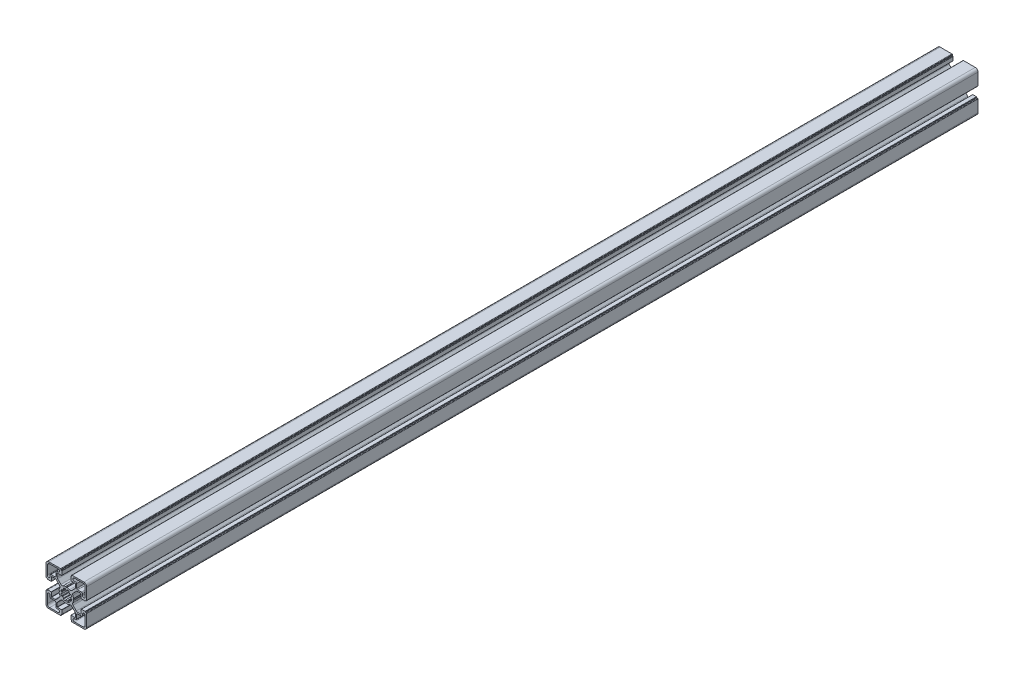
from build123d import *

# Parameters (mm, degrees)
BASE_EXTRUDE_DEPTH = 988


with BuildPart() as part:
    # Sketch1 → Base-Extrude (new body)
    with BuildSketch(Plane.XY):
        with BuildLine():
            Line((7.973976585, 0.792591518), (7.540060475, 0.046829556))
            ThreePointArc((7.540060475, 0.046829556), (7.534295984, 0.023675638), (7.531329941, 0))
            ThreePointArc((7.531329941, 0), (7.534295984, -0.023675638), (7.540060475, -0.046829556))
            Line((7.540060475, -0.046829556), (7.973976585, -0.792591518))
            ThreePointArc((7.973976585, -0.792591518), (7.996666421, -0.851255641), (8.000014047, -0.914065683))
            ThreePointArc((8.000014047, -0.914065683), (7.719730741, -2.298395946), (7.20036345, -3.611859543))
            ThreePointArc((7.20036345, -3.611859543), (7.018857217, -4.793954471), (7.563483933, -5.85869607))
            Line((7.563483933, -5.85869607), (11.129779889, -9.424988026))
            ThreePointArc((11.129779889, -9.424988026), (11.760624613, -9.84650461), (12.504756513, -9.99452154))
            Line((12.504756513, -9.99452154), (16.316902451, -9.99452154))
            ThreePointArc((16.316902451, -9.99452154), (16.458324055, -9.935942793), (16.516902802, -9.794521189))
            Line((16.516902802, -9.794521189), (16.516902802, -5.200014226))
            ThreePointArc((16.516902802, -5.200014226), (16.575481548, -5.058592621), (16.716903152, -5.000013875))
            Line((16.716903152, -5.000013875), (20.719599904, -5.000013875))
            ThreePointArc((20.719599904, -5.000013875), (20.931731427, -5.087881629), (21.01959918, -5.300013151))
            Line((21.01959918, -5.300013151), (21.01959918, -5.500004099))
            ThreePointArc((21.01959918, -5.500004099), (21.10746708, -5.712135974), (21.319598956, -5.800003874))
            Line((21.319598956, -5.800003874), (21.999979514, -5.800003874))
            ThreePointArc((21.999979514, -5.800003874), (22.35353264, -5.946450374), (22.49997914, -6.300003501))
            Line((22.49997914, -6.300003501), (22.49997914, -19.500016116))
            ThreePointArc((22.49997914, -19.500016116), (21.62130014, -21.621334875), (19.499981381, -22.500013875))
            Line((19.499981381, -22.500013875), (6.375709012, -22.500013875))
            ThreePointArc((6.375709012, -22.500013875), (6.022155886, -22.353567375), (5.875709386, -22.000014249))
            Line((5.875709386, -22.000014249), (5.875709386, -21.30001315))
            ThreePointArc((5.875709386, -21.30001315), (5.787841632, -21.087881628), (5.57571011, -21.000013874))
            Line((5.57571011, -21.000013874), (5.299998776, -21.000013874))
            ThreePointArc((5.299998776, -21.000013874), (5.087867607, -20.912146267), (5, -20.700015099))
            Line((5, -20.700015099), (5, -16.666812433))
            ThreePointArc((5, -16.666812433), (5.058578893, -16.525390475), (5.200000851, -16.466811582))
            Line((5.200000851, -16.466811582), (9.905385218, -16.466811582))
            ThreePointArc((9.905385218, -16.466811582), (10.046806822, -16.408232835), (10.105385569, -16.266811231))
            Line((10.105385569, -16.266811231), (10.105385569, -12.471582956))
            ThreePointArc((10.105385569, -12.471582956), (9.953144588, -11.706215861), (9.519598955, -11.057368968))
            Line((9.519598955, -11.057368968), (5.944897989, -7.482668002))
            ThreePointArc((5.944897989, -7.482668002), (4.854601835, -6.967833724), (3.666499237, -7.173289937))
            ThreePointArc((3.666499237, -7.173289937), (2.309136684, -7.713848333), (0.876396038, -8.000013875))
            ThreePointArc((0.876396038, -8.000013875), (0.81356491, -7.997088573), (0.754749577, -7.974793627))
            Line((0.754749577, -7.974793627), (0.11262846, -7.606936933))
            ThreePointArc((0.11262846, -7.606936933), (0.062963903, -7.559088739), (0, -7.530953975))
            ThreePointArc((0, -7.530953975), (-0.062963903, -7.559088739), (-0.11262846, -7.606936933))
            Line((-0.11262846, -7.606936933), (-0.754749577, -7.974793627))
            ThreePointArc((-0.754749577, -7.974793627), (-0.81356491, -7.997088573), (-0.876396038, -8.000013875))
            ThreePointArc((-0.876396038, -8.000013875), (-2.309136684, -7.713848333), (-3.666499237, -7.173289937))
            ThreePointArc((-3.666499237, -7.173289937), (-4.854601835, -6.967833724), (-5.944897989, -7.482668002))
            Line((-5.944897989, -7.482668002), (-9.519598955, -11.057368968))
            ThreePointArc((-9.519598955, -11.057368968), (-9.953144588, -11.706215861), (-10.105385569, -12.471582956))
            Line((-10.105385569, -12.471582956), (-10.105385569, -16.266811231))
            ThreePointArc((-10.105385569, -16.266811231), (-10.046806822, -16.408232835), (-9.905385218, -16.466811582))
            Line((-9.905385218, -16.466811582), (-5.200000851, -16.466811582))
            ThreePointArc((-5.200000851, -16.466811582), (-5.058578893, -16.525390475), (-5, -16.666812433))
            Line((-5, -16.666812433), (-5, -20.700015099))
            ThreePointArc((-5, -20.700015099), (-5.087867607, -20.912146267), (-5.299998776, -21.000013874))
            Line((-5.299998776, -21.000013874), (-5.57571011, -21.000013874))
            ThreePointArc((-5.57571011, -21.000013874), (-5.787841632, -21.087881628), (-5.875709386, -21.30001315))
            Line((-5.875709386, -21.30001315), (-5.875709386, -22.000014249))
            ThreePointArc((-5.875709386, -22.000014249), (-6.022155886, -22.353567375), (-6.375709012, -22.500013875))
            Line((-6.375709012, -22.500013875), (-19.499981381, -22.500013875))
            ThreePointArc((-19.499981381, -22.500013875), (-21.62130014, -21.621334875), (-22.49997914, -19.500016116))
            Line((-22.49997914, -19.500016116), (-22.49997914, -6.300003501))
            ThreePointArc((-22.49997914, -6.300003501), (-22.35353264, -5.946450374), (-21.999979514, -5.800003874))
            Line((-21.999979514, -5.800003874), (-21.319598956, -5.800003874))
            ThreePointArc((-21.319598956, -5.800003874), (-21.10746708, -5.712135974), (-21.01959918, -5.500004099))
            Line((-21.01959918, -5.500004099), (-21.01959918, -5.300013151))
            ThreePointArc((-21.01959918, -5.300013151), (-20.931731427, -5.087881629), (-20.719599904, -5.000013875))
            Line((-20.719599904, -5.000013875), (-16.716903152, -5.000013875))
            ThreePointArc((-16.716903152, -5.000013875), (-16.575481548, -5.058592621), (-16.516902802, -5.200014226))
            Line((-16.516902802, -5.200014226), (-16.516902802, -9.794521189))
            ThreePointArc((-16.516902802, -9.794521189), (-16.458324055, -9.935942793), (-16.316902451, -9.99452154))
            Line((-16.316902451, -9.99452154), (-12.504756513, -9.99452154))
            ThreePointArc((-12.504756513, -9.99452154), (-11.760624613, -9.84650461), (-11.129779889, -9.424988026))
            Line((-11.129779889, -9.424988026), (-7.563483933, -5.85869607))
            ThreePointArc((-7.563483933, -5.85869607), (-7.018857217, -4.793954471), (-7.20036345, -3.611859543))
            ThreePointArc((-7.20036345, -3.611859543), (-7.719730741, -2.298395946), (-8.000014047, -0.914065683))
            ThreePointArc((-8.000014047, -0.914065683), (-7.996666421, -0.851255641), (-7.973976585, -0.792591518))
            Line((-7.973976585, -0.792591518), (-7.540060475, -0.046829556))
            ThreePointArc((-7.540060475, -0.046829556), (-7.534295984, -0.023675638), (-7.531329941, 0))
            ThreePointArc((-7.531329941, 0), (-7.534295984, 0.023675638), (-7.540060475, 0.046829556))
            Line((-7.540060475, 0.046829556), (-7.973976585, 0.792591518))
            ThreePointArc((-7.973976585, 0.792591518), (-7.996666421, 0.851255641), (-8.000014047, 0.914065683))
            ThreePointArc((-8.000014047, 0.914065683), (-7.719730741, 2.298395946), (-7.20036345, 3.611859543))
            ThreePointArc((-7.20036345, 3.611859543), (-7.018857217, 4.793954471), (-7.563483933, 5.85869607))
            Line((-7.563483933, 5.85869607), (-11.129779889, 9.424988026))
            ThreePointArc((-11.129779889, 9.424988026), (-11.760624613, 9.84650461), (-12.504756513, 9.99452154))
            Line((-12.504756513, 9.99452154), (-16.316902451, 9.99452154))
            ThreePointArc((-16.316902451, 9.99452154), (-16.458324055, 9.935942793), (-16.516902802, 9.794521189))
            Line((-16.516902802, 9.794521189), (-16.516902802, 5.200014226))
            ThreePointArc((-16.516902802, 5.200014226), (-16.575481548, 5.058592621), (-16.716903152, 5.000013875))
            Line((-16.716903152, 5.000013875), (-20.719599904, 5.000013875))
            ThreePointArc((-20.719599904, 5.000013875), (-20.931731427, 5.087881629), (-21.01959918, 5.300013151))
            Line((-21.01959918, 5.300013151), (-21.01959918, 5.500004099))
            ThreePointArc((-21.01959918, 5.500004099), (-21.10746708, 5.712135974), (-21.319598956, 5.800003874))
            Line((-21.319598956, 5.800003874), (-21.999979514, 5.800003874))
            ThreePointArc((-21.999979514, 5.800003874), (-22.35353264, 5.946450374), (-22.49997914, 6.300003501))
            Line((-22.49997914, 6.300003501), (-22.49997914, 19.500016116))
            ThreePointArc((-22.49997914, 19.500016116), (-21.62130014, 21.621334875), (-19.499981381, 22.500013875))
            Line((-19.499981381, 22.500013875), (-6.375709012, 22.500013875))
            ThreePointArc((-6.375709012, 22.500013875), (-6.022155886, 22.353567375), (-5.875709386, 22.000014249))
            Line((-5.875709386, 22.000014249), (-5.875709386, 21.30001315))
            ThreePointArc((-5.875709386, 21.30001315), (-5.787841632, 21.087881628), (-5.57571011, 21.000013874))
            Line((-5.57571011, 21.000013874), (-5.299998776, 21.000013874))
            ThreePointArc((-5.299998776, 21.000013874), (-5.087867607, 20.912146267), (-5, 20.700015099))
            Line((-5, 20.700015099), (-5, 16.666812433))
            ThreePointArc((-5, 16.666812433), (-5.058578893, 16.525390475), (-5.200000851, 16.466811582))
            Line((-5.200000851, 16.466811582), (-9.905385218, 16.466811582))
            ThreePointArc((-9.905385218, 16.466811582), (-10.046806822, 16.408232835), (-10.105385569, 16.266811231))
            Line((-10.105385569, 16.266811231), (-10.105385569, 12.471582956))
            ThreePointArc((-10.105385569, 12.471582956), (-9.953144588, 11.706215861), (-9.519598955, 11.057368968))
            Line((-9.519598955, 11.057368968), (-5.944897989, 7.482668002))
            ThreePointArc((-5.944897989, 7.482668002), (-4.854601835, 6.967833724), (-3.666499237, 7.173289937))
            ThreePointArc((-3.666499237, 7.173289937), (-2.309136684, 7.713848333), (-0.876396038, 8.000013875))
            ThreePointArc((-0.876396038, 8.000013875), (-0.81356491, 7.997088573), (-0.754749577, 7.974793627))
            Line((-0.754749577, 7.974793627), (-0.11262846, 7.606936933))
            ThreePointArc((-0.11262846, 7.606936933), (-0.062963903, 7.559088739), (0, 7.530953975))
            ThreePointArc((0, 7.530953975), (0.062963903, 7.559088739), (0.11262846, 7.606936933))
            Line((0.11262846, 7.606936933), (0.754749577, 7.974793627))
            ThreePointArc((0.754749577, 7.974793627), (0.81356491, 7.997088573), (0.876396038, 8.000013875))
            ThreePointArc((0.876396038, 8.000013875), (2.309136684, 7.713848333), (3.666499237, 7.173289937))
            ThreePointArc((3.666499237, 7.173289937), (4.854601835, 6.967833724), (5.944897989, 7.482668002))
            Line((5.944897989, 7.482668002), (9.519598955, 11.057368968))
            ThreePointArc((9.519598955, 11.057368968), (9.953144588, 11.706215861), (10.105385569, 12.471582956))
            Line((10.105385569, 12.471582956), (10.105385569, 16.266811231))
            ThreePointArc((10.105385569, 16.266811231), (10.046806822, 16.408232835), (9.905385218, 16.466811582))
            Line((9.905385218, 16.466811582), (5.200000851, 16.466811582))
            ThreePointArc((5.200000851, 16.466811582), (5.058578893, 16.525390475), (5, 16.666812433))
            Line((5, 16.666812433), (5, 20.700015099))
            ThreePointArc((5, 20.700015099), (5.087867607, 20.912146267), (5.299998776, 21.000013874))
            Line((5.299998776, 21.000013874), (5.57571011, 21.000013874))
            ThreePointArc((5.57571011, 21.000013874), (5.787841632, 21.087881628), (5.875709386, 21.30001315))
            Line((5.875709386, 21.30001315), (5.875709386, 22.000014249))
            ThreePointArc((5.875709386, 22.000014249), (6.022155886, 22.353567375), (6.375709012, 22.500013875))
            Line((6.375709012, 22.500013875), (19.499981381, 22.500013875))
            ThreePointArc((19.499981381, 22.500013875), (21.62130014, 21.621334875), (22.49997914, 19.500016116))
            Line((22.49997914, 19.500016116), (22.49997914, 6.300003501))
            ThreePointArc((22.49997914, 6.300003501), (22.35353264, 5.946450374), (21.999979514, 5.800003874))
            Line((21.999979514, 5.800003874), (21.319598956, 5.800003874))
            ThreePointArc((21.319598956, 5.800003874), (21.10746708, 5.712135974), (21.01959918, 5.500004099))
            Line((21.01959918, 5.500004099), (21.01959918, 5.300013151))
            ThreePointArc((21.01959918, 5.300013151), (20.931731427, 5.087881629), (20.719599904, 5.000013875))
            Line((20.719599904, 5.000013875), (16.716903152, 5.000013875))
            ThreePointArc((16.716903152, 5.000013875), (16.575481548, 5.058592621), (16.516902802, 5.200014226))
            Line((16.516902802, 5.200014226), (16.516902802, 9.794521189))
            ThreePointArc((16.516902802, 9.794521189), (16.458324055, 9.935942793), (16.316902451, 9.99452154))
            Line((16.316902451, 9.99452154), (12.504756513, 9.99452154))
            ThreePointArc((12.504756513, 9.99452154), (11.760624613, 9.84650461), (11.129779889, 9.424988026))
            Line((11.129779889, 9.424988026), (7.563483933, 5.85869607))
            ThreePointArc((7.563483933, 5.85869607), (7.018857217, 4.793954471), (7.20036345, 3.611859543))
            ThreePointArc((7.20036345, 3.611859543), (7.719730741, 2.298395946), (8.000014047, 0.914065683))
            ThreePointArc((8.000014047, 0.914065683), (7.996666421, 0.851255641), (7.973976585, 0.792591518))
        make_face()
        with BuildLine():
            Line((10.549978885, 18.000013874), (8.999979138, 18.000013874))
            ThreePointArc((8.999979138, 18.000013874), (7.499979138, 19.500013874), (8.999979138, 21.000013874))
            Line((8.999979138, 21.000013874), (18.499981006, 21.000013874))
            ThreePointArc((18.499981006, 21.000013874), (20.267746638, 20.267781374), (20.999979138, 18.500015742))
            Line((20.999979138, 18.500015742), (20.999979138, 9.000204874))
            ThreePointArc((20.999979138, 9.000204874), (19.499979138, 7.500204874), (17.999979138, 9.000204874))
            Line((17.999979138, 9.000204874), (17.999979138, 10.550013621))
            ThreePointArc((17.999979138, 10.550013621), (17.707086138, 11.257119874), (16.999979885, 11.550012874))
            Line((16.999979885, 11.550012874), (12.549977391, 11.550012874))
            ThreePointArc((12.549977391, 11.550012874), (11.842871138, 11.842905874), (11.549978138, 12.550012127))
            Line((11.549978138, 12.550012127), (11.549978138, 17.000014621))
            ThreePointArc((11.549978138, 17.000014621), (11.257085138, 17.707120874), (10.549978885, 18.000013874))
        make_face(mode=Mode.SUBTRACT)
        with BuildLine():
            Line((-0.867388737, 4.924188946), (-0.96752168, 5.481112935))
            ThreePointArc((-0.96752168, 5.481112935), (-1.187855719, 5.829589164), (-1.595071417, 5.894072848))
            ThreePointArc((-1.595071417, 5.894072848), (-2.338895973, 5.643477696), (-3.04438497, 5.299445466))
            ThreePointArc((-3.04438497, 5.299445466), (-3.284615367, 4.964275075), (-3.191311906, 4.562598216))
            Line((-3.191311906, 4.562598216), (-2.864000421, 4.09847552))
            ThreePointArc((-2.864000421, 4.09847552), (-3.53013295, 3.540926624), (-4.08971289, 2.876499344))
            Line((-4.08971289, 2.876499344), (-4.566777651, 3.208162503))
            ThreePointArc((-4.566777651, 3.208162503), (-4.968960845, 3.298770682), (-5.302497889, 3.056460542))
            ThreePointArc((-5.302497889, 3.056460542), (-5.651259984, 2.353310881), (-5.906847665, 1.611199444))
            ThreePointArc((-5.906847665, 1.611199444), (-5.839752063, 1.204293023), (-5.489730697, 0.98621116))
            Line((-5.489730697, 0.98621116), (-4.920545766, 0.887822825))
            ThreePointArc((-4.920545766, 0.887822825), (-4.980096828, 0.445685524), (-5, 0))
            ThreePointArc((-5, 0), (-4.980096828, -0.445685524), (-4.920545766, -0.887822825))
            Line((-4.920545766, -0.887822825), (-5.489730697, -0.98621116))
            ThreePointArc((-5.489730697, -0.98621116), (-5.839752063, -1.204293023), (-5.906847665, -1.611199444))
            ThreePointArc((-5.906847665, -1.611199444), (-5.651259984, -2.353310881), (-5.302497889, -3.056460542))
            ThreePointArc((-5.302497889, -3.056460542), (-4.968960845, -3.298770682), (-4.566777651, -3.208162503))
            Line((-4.566777651, -3.208162503), (-4.08971289, -2.876499344))
            ThreePointArc((-4.08971289, -2.876499344), (-3.53013295, -3.540926624), (-2.864000421, -4.09847552))
            Line((-2.864000421, -4.09847552), (-3.191311906, -4.562598216))
            ThreePointArc((-3.191311906, -4.562598216), (-3.284615367, -4.964275075), (-3.04438497, -5.299445466))
            ThreePointArc((-3.04438497, -5.299445466), (-2.338895973, -5.643477696), (-1.595071417, -5.894072848))
            ThreePointArc((-1.595071417, -5.894072848), (-1.187855719, -5.829589164), (-0.96752168, -5.481112935))
            Line((-0.96752168, -5.481112935), (-0.867388737, -4.924188946))
            ThreePointArc((-0.867388737, -4.924188946), (0, -5), (0.867388737, -4.924188946))
            Line((0.867388737, -4.924188946), (0.96752168, -5.481112935))
            ThreePointArc((0.96752168, -5.481112935), (1.187855719, -5.829589164), (1.595071417, -5.894072848))
            ThreePointArc((1.595071417, -5.894072848), (2.338895973, -5.643477696), (3.04438497, -5.299445466))
            ThreePointArc((3.04438497, -5.299445466), (3.284615367, -4.964275075), (3.191311906, -4.562598216))
            Line((3.191311906, -4.562598216), (2.864000421, -4.09847552))
            ThreePointArc((2.864000421, -4.09847552), (3.53013295, -3.540926624), (4.08971289, -2.876499344))
            Line((4.08971289, -2.876499344), (4.566777651, -3.208162503))
            ThreePointArc((4.566777651, -3.208162503), (4.968960845, -3.298770682), (5.302497889, -3.056460542))
            ThreePointArc((5.302497889, -3.056460542), (5.651259984, -2.353310881), (5.906847665, -1.611199444))
            ThreePointArc((5.906847665, -1.611199444), (5.839752063, -1.204293023), (5.489730697, -0.98621116))
            Line((5.489730697, -0.98621116), (4.920545766, -0.887822825))
            ThreePointArc((4.920545766, -0.887822825), (4.980096828, -0.445685524), (5, 0))
            ThreePointArc((5, 0), (4.980096828, 0.445685524), (4.920545766, 0.887822825))
            Line((4.920545766, 0.887822825), (5.489730697, 0.98621116))
            ThreePointArc((5.489730697, 0.98621116), (5.839752063, 1.204293023), (5.906847665, 1.611199444))
            ThreePointArc((5.906847665, 1.611199444), (5.651259984, 2.353310881), (5.302497889, 3.056460542))
            ThreePointArc((5.302497889, 3.056460542), (4.968960845, 3.298770682), (4.566777651, 3.208162503))
            Line((4.566777651, 3.208162503), (4.08971289, 2.876499344))
            ThreePointArc((4.08971289, 2.876499344), (3.53013295, 3.540926624), (2.864000421, 4.09847552))
            Line((2.864000421, 4.09847552), (3.191311906, 4.562598216))
            ThreePointArc((3.191311906, 4.562598216), (3.284615367, 4.964275075), (3.04438497, 5.299445466))
            ThreePointArc((3.04438497, 5.299445466), (2.338895973, 5.643477696), (1.595071417, 5.894072848))
            ThreePointArc((1.595071417, 5.894072848), (1.187855719, 5.829589164), (0.96752168, 5.481112935))
            Line((0.96752168, 5.481112935), (0.867388737, 4.924188946))
            ThreePointArc((0.867388737, 4.924188946), (0, 5), (-0.867388737, 4.924188946))
        make_face(mode=Mode.SUBTRACT)
        with BuildLine():
            Line((-10.549978885, -18.000013874), (-8.999979138, -18.000013874))
            ThreePointArc((-8.999979138, -18.000013874), (-7.499979138, -19.500013874), (-8.999979138, -21.000013874))
            Line((-8.999979138, -21.000013874), (-18.499981006, -21.000013874))
            ThreePointArc((-18.499981006, -21.000013874), (-20.267746638, -20.267781374), (-20.999979138, -18.500015742))
            Line((-20.999979138, -18.500015742), (-20.999979138, -9.000204874))
            ThreePointArc((-20.999979138, -9.000204874), (-19.499979138, -7.500204874), (-17.999979138, -9.000204874))
            Line((-17.999979138, -9.000204874), (-17.999979138, -10.550013621))
            ThreePointArc((-17.999979138, -10.550013621), (-17.707086138, -11.257119874), (-16.999979885, -11.550012874))
            Line((-16.999979885, -11.550012874), (-12.549977391, -11.550012874))
            ThreePointArc((-12.549977391, -11.550012874), (-11.842871138, -11.842905874), (-11.549978138, -12.550012127))
            Line((-11.549978138, -12.550012127), (-11.549978138, -17.000014621))
            ThreePointArc((-11.549978138, -17.000014621), (-11.257085138, -17.707120874), (-10.549978885, -18.000013874))
        make_face(mode=Mode.SUBTRACT)
        with BuildLine():
            Line((-11.549978138, 12.550012127), (-11.549978138, 17.000014621))
            ThreePointArc((-11.549978138, 17.000014621), (-11.257085138, 17.707120874), (-10.549978885, 18.000013874))
            Line((-10.549978885, 18.000013874), (-8.999979138, 18.000013874))
            ThreePointArc((-8.999979138, 18.000013874), (-7.499979138, 19.500013874), (-8.999979138, 21.000013874))
            Line((-8.999979138, 21.000013874), (-18.499981006, 21.000013874))
            ThreePointArc((-18.499981006, 21.000013874), (-20.267746638, 20.267781374), (-20.999979138, 18.500015742))
            Line((-20.999979138, 18.500015742), (-20.999979138, 9.000204874))
            ThreePointArc((-20.999979138, 9.000204874), (-19.499979138, 7.500204874), (-17.999979138, 9.000204874))
            Line((-17.999979138, 9.000204874), (-17.999979138, 10.550013621))
            ThreePointArc((-17.999979138, 10.550013621), (-17.707086138, 11.257119874), (-16.999979885, 11.550012874))
            Line((-16.999979885, 11.550012874), (-12.549977391, 11.550012874))
            ThreePointArc((-12.549977391, 11.550012874), (-11.842871138, 11.842905874), (-11.549978138, 12.550012127))
        make_face(mode=Mode.SUBTRACT)
        with BuildLine():
            Line((11.549978138, -12.550012127), (11.549978138, -17.000014621))
            ThreePointArc((11.549978138, -17.000014621), (11.257085138, -17.707120874), (10.549978885, -18.000013874))
            Line((10.549978885, -18.000013874), (8.999979138, -18.000013874))
            ThreePointArc((8.999979138, -18.000013874), (7.499979138, -19.500013874), (8.999979138, -21.000013874))
            Line((8.999979138, -21.000013874), (18.499981006, -21.000013874))
            ThreePointArc((18.499981006, -21.000013874), (20.267746638, -20.267781374), (20.999979138, -18.500015742))
            Line((20.999979138, -18.500015742), (20.999979138, -9.000204874))
            ThreePointArc((20.999979138, -9.000204874), (19.499979138, -7.500204874), (17.999979138, -9.000204874))
            Line((17.999979138, -9.000204874), (17.999979138, -10.550013621))
            ThreePointArc((17.999979138, -10.550013621), (17.707086138, -11.257119874), (16.999979885, -11.550012874))
            Line((16.999979885, -11.550012874), (12.549977391, -11.550012874))
            ThreePointArc((12.549977391, -11.550012874), (11.842871138, -11.842905874), (11.549978138, -12.550012127))
        make_face(mode=Mode.SUBTRACT)
    extrude(amount=-BASE_EXTRUDE_DEPTH)


solid = part.part
